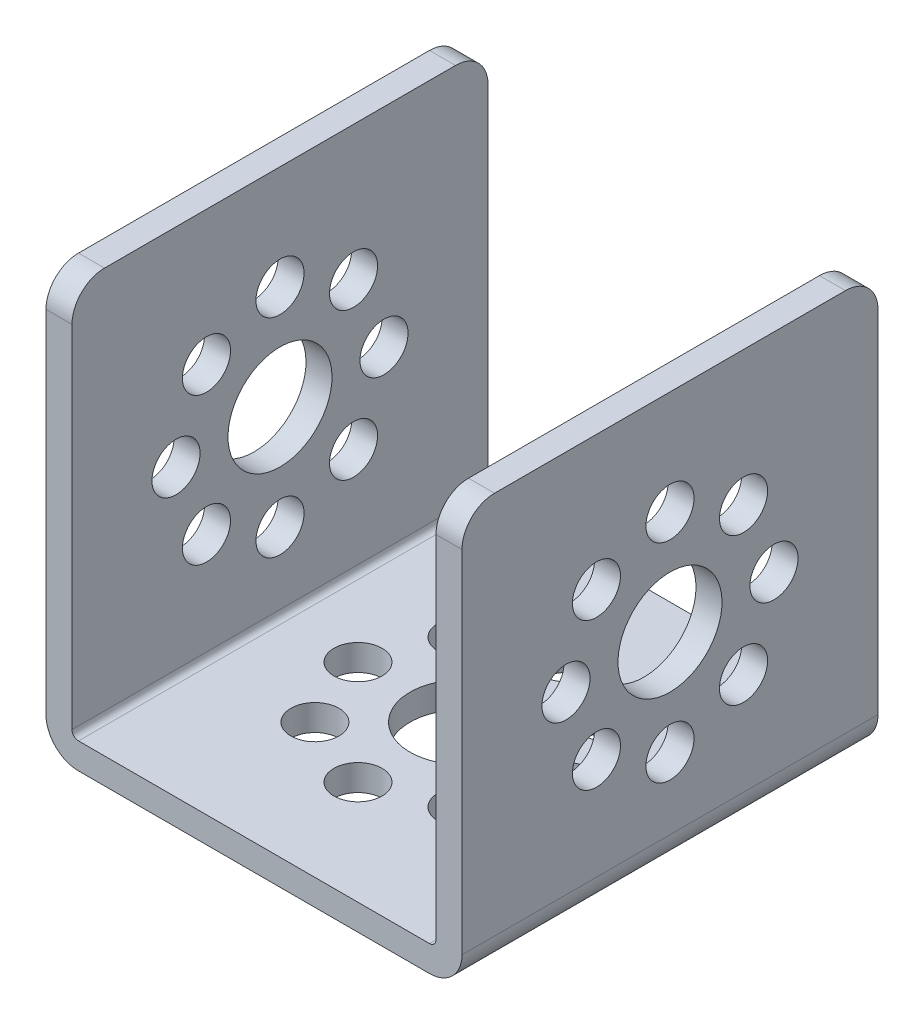
from build123d import *

# Parameters (mm, degrees)
EXTRUDE1_DEPTH     = 16
FILLET1_R          = 2.5
SKETCH2_R          = 4
CUT_EXTRUDE1_DEPTH = 33
SKETCH3_R          = 4
CUT_EXTRUDE3_DEPTH = 33
SKETCH3_3_R        = 1.85
CUT_EXTRUDE4_DEPTH = 33
SKETCH2_4_R        = 1.85
CUT_EXTRUDE2_DEPTH = 33
CIRPATTERN1_COUNT  = 8
CIRPATTERN3_COUNT  = 8


with BuildPart() as part:
    # Sketch1 → Extrude1 (new body, symmetric)
    with BuildSketch(Plane.XY):
        with BuildLine():
            Line((-13.5, 0), (13.5, 0))
            ThreePointArc((13.5, 0), (15.267766953, 0.732233047), (16, 2.5))
            Line((16, 2.5), (16, 32))
            Line((16, 32), (14, 32))
            Line((14, 32), (14, 2.5))
            ThreePointArc((14, 2.5), (13.853553391, 2.146446609), (13.5, 2))
            Line((13.5, 2), (-13.5, 2))
            ThreePointArc((-13.5, 2), (-13.853553391, 2.146446609), (-14, 2.5))
            Line((-14, 2.5), (-14, 32))
            Line((-14, 32), (-16, 32))
            Line((-16, 32), (-16, 2.5))
            ThreePointArc((-16, 2.5), (-15.267766953, 0.732233047), (-13.5, 0))
        make_face()
    extrude(amount=EXTRUDE1_DEPTH, both=True)

    # Fillet1
    fillet1_edges = [part.edges().sort_by_distance(p)[0] for p in [
        (-15, 32, -16),
        (-15, 32, 16),
        (15, 32, -16),
        (15, 32, 16),
    ]]
    fillet(fillet1_edges, radius=FILLET1_R)

    # Sketch2 → Cut-Extrude1 (cut, through all)
    with BuildSketch(Plane.XZ):
        Circle(SKETCH2_R)
    extrude(amount=-CUT_EXTRUDE1_DEPTH, mode=Mode.SUBTRACT)

    # Sketch3 → Cut-Extrude3 (cut, through all)
    with BuildSketch(Plane.ZY.offset(16)):
        with Locations((0, 16)):
            Circle(SKETCH3_R)
    extrude(amount=-CUT_EXTRUDE3_DEPTH, mode=Mode.SUBTRACT)

    # Sketch3_3 → Cut-Extrude4 (cut, through all)
    with BuildSketch(Plane.ZY.offset(16)):
        with Locations((0, 8)):
            Circle(SKETCH3_3_R)
    cut_extrude4 = extrude(amount=-CUT_EXTRUDE4_DEPTH, mode=Mode.SUBTRACT)

    # Sketch2_4 → Cut-Extrude2 (cut, through all)
    with BuildSketch(Plane.XZ):
        with Locations((8, 0)):
            Circle(SKETCH2_4_R)
    cut_extrude2 = extrude(amount=-CUT_EXTRUDE2_DEPTH, mode=Mode.SUBTRACT)

    # CirPattern1: Cut-Extrude2 ×8 about axis
    cirpattern1_axis = Axis((0, 0, 0), (0, 1, 0))
    for i in range(1, CIRPATTERN1_COUNT):
        add(cut_extrude2.rotate(cirpattern1_axis, i * 360 / CIRPATTERN1_COUNT), mode=Mode.SUBTRACT)

    # CirPattern3: Cut-Extrude4 ×8 about axis
    cirpattern3_axis = Axis((0, 16, 0), (1, 0, 0))
    for i in range(1, CIRPATTERN3_COUNT):
        add(cut_extrude4.rotate(cirpattern3_axis, i * 360 / CIRPATTERN3_COUNT), mode=Mode.SUBTRACT)


solid = part.part
